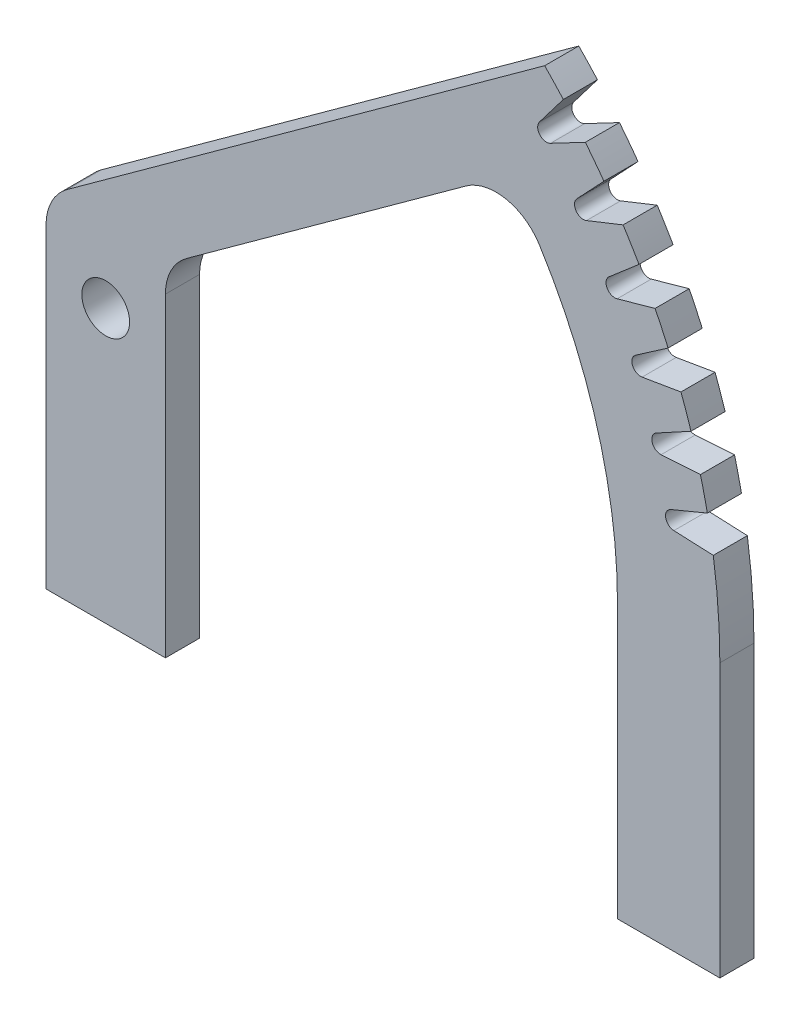
from build123d import *

# Parameters (mm, degrees)
ESQUISSE1_R        = 7
BOSS_EXTRU_2_DEPTH = 5


with BuildPart() as part:
    # Esquisse1 → Boss.-Extru.2 (new body, symmetric)
    with BuildSketch(Plane.XY):
        with BuildLine():
            Line((150, 0), (150, -80))
            Line((150, -80), (180, -80))
            Line((180, -80), (180, 0))
            ThreePointArc((180, 0), (179.515656817, 13.195793174), (178.065233806, 26.320571987))
            Line((178.065233806, 26.320571987), (166.525661597, 26.82440059))
            ThreePointArc((166.525661597, 26.82440059), (164.115561692, 28.93800148), (165.657420708, 31.748439355))
            Line((165.657420708, 31.748439355), (176.328752029, 36.168649517))
            ThreePointArc((176.328752029, 36.168649517), (175.369530112, 40.565107028), (174.300707948, 44.936212668))
            Line((174.300707948, 44.936212668), (162.772284789, 44.221349389))
            ThreePointArc((162.772284789, 44.221349389), (160.152897605, 46.069240364), (161.390047035, 49.026494422))
            Line((161.390047035, 49.026494422), (171.536232439, 54.546502735))
            ThreePointArc((171.536232439, 54.546502735), (170.119109634, 58.817416956), (168.595667923, 63.051572207))
            Line((168.595667923, 63.051572207), (157.206741362, 61.125975718))
            ThreePointArc((157.206741362, 61.125975718), (154.407228903, 62.687583949), (155.325895389, 65.758730667))
            Line((155.325895389, 65.758730667), (164.833975975, 72.317082106))
            ThreePointArc((164.833975975, 72.317082106), (162.974729307, 76.414904352), (161.013628739, 80.464969771))
            Line((161.013628739, 80.464969771), (149.89099329, 77.350078007))
            ThreePointArc((149.89099329, 77.350078007), (146.94252292, 78.608017892), (147.532478818, 81.758865764))
            Line((147.532478818, 81.758865764), (156.296599795, 89.282545285))
            ThreePointArc((156.296599795, 89.282545285), (154.015928519, 93.161653928), (151.6390023, 96.98253957))
            Line((151.6390023, 96.98253957), (140.906487819, 92.713031056))
            ThreePointArc((140.906487819, 92.713031056), (137.841885271, 93.653297773), (138.09656252, 96.84876797))
            Line((138.09656252, 96.84876797), (146.019151703, 105.254013396))
            ThreePointArc((146.019151703, 105.254013396), (143.34244685, 108.871221776), (140.576157634, 112.420389187))
            Line((140.576157634, 112.420389187), (130.353250706, 107.04379696))
            ThreePointArc((130.353250706, 107.04379696), (127.206634629, 107.655922389), (127.123197872, 110.860439292))
            Line((127.123197872, 110.860439292), (134.116051966, 120.053673851))
            ThreePointArc((134.116051966, 120.053673851), (131.415298407, 123.004143608), (128.649651075, 125.893873077))
            Line((128.649651075, 125.893873077), (104.03484123, 108.059020032))
            Line((104.03484123, 108.059020032), (-11.300992684, 24.491539248))
            ThreePointArc((-11.300992684, 24.491539248), (-15.86066784, 19.163375655), (-17.5, 12.344830732))
            Line((-17.5, 12.344830732), (-17.5, -80))
            Line((-17.5, -80), (17.5, -80))
            Line((17.5, -80), (17.5, 12.344830732))
            ThreePointArc((17.5, 12.344830732), (19.13933216, 19.163375655), (23.699007316, 24.491539248))
            Line((23.699007316, 24.491539248), (105.595221964, 83.83008228))
            ThreePointArc((105.595221964, 83.83008228), (117.258640826, 86.4077249), (127.106905164, 79.648193071))
            ThreePointArc((127.106905164, 79.648193071), (144.163164114, 41.436482871), (150, 0))
        make_face()
        Circle(ESQUISSE1_R, mode=Mode.SUBTRACT)
    extrude(amount=BOSS_EXTRU_2_DEPTH, both=True)


solid = part.part
